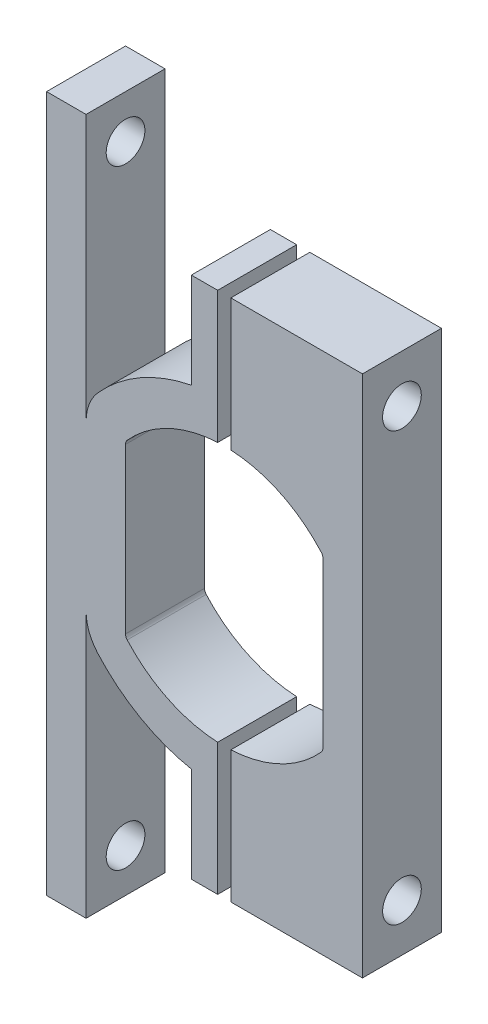
from build123d import *

# Parameters (mm, degrees)
SKETCH1_W           = 65
SKETCH1_H           = 65
BOSS_EXTRUDE1_DEPTH = 6
SKETCH3_W           = 65
SKETCH3_H           = 65
CUT_EXTRUDE2_DEPTH  = 10
BOSS_EXTRUDE2_DEPTH = 6
CUT_EXTRUDE3_REACH  = 39.726
CUT_EXTRUDE4_START  = -13
SKETCH7_R           = 1.47
CUT_EXTRUDE4_DEPTH  = 13
SKETCH8_W           = 6
SKETCH8_H           = 6.572516921
SKETCH8_R           = 1.47
SKETCH8_H_2         = 13.638765158
SKETCH8_H_3         = 12.472469684
BOSS_EXTRUDE3_DEPTH = 3


with BuildPart() as part:
    # Sketch1 → Boss-Extrude1 (new body)
    with BuildSketch(Plane.XY):
        Rectangle(SKETCH1_W, SKETCH1_H)
    extrude(amount=BOSS_EXTRUDE1_DEPTH)

    # Sketch3 → Cut-Extrude2 (cut)
    with BuildSketch(Plane.XY.offset(6)):
        Rectangle(SKETCH3_W, SKETCH3_H)
        with BuildLine():
            Line((10.5, 4.597893539), (10.5, 6.236234842))
            ThreePointArc((10.5, 6.236234842), (10.729169321, 7.481893971), (11.386666667, 8.564429183))
            ThreePointArc((11.386666667, 8.564429183), (21, 12.875), (30.613333333, 8.564429183))
            ThreePointArc((30.613333333, 8.564429183), (31.270830679, 7.481893971), (31.5, 6.236234842))
            Line((31.5, 6.236234842), (31.5, 4.597893539))
            Line((31.5, 4.597893539), (31.5, -4.597893539))
            Line((31.5, -4.597893539), (31.5, -6.236234842))
            ThreePointArc((31.5, -6.236234842), (31.270830679, -7.481893971), (30.613333333, -8.564429183))
            ThreePointArc((30.613333333, -8.564429183), (21, -12.875), (11.386666667, -8.564429183))
            ThreePointArc((11.386666667, -8.564429183), (10.729169321, -7.481893971), (10.5, -6.236234842))
            Line((10.5, -6.236234842), (10.5, -4.597893539))
            Line((10.5, -4.597893539), (10.5, 4.597893539))
        make_face(mode=Mode.SUBTRACT)
        with BuildLine():
            ThreePointArc((28.5, 6.236234842), (28.467261526, 6.414186146), (28.373333333, 6.568834033))
            ThreePointArc((28.373333333, 6.568834033), (21, 9.875), (13.626666667, 6.568834033))
            ThreePointArc((13.626666667, 6.568834033), (13.532738474, 6.414186146), (13.5, 6.236234842))
            Line((13.5, 6.236234842), (13.5, 4.597893539))
            Line((13.5, 4.597893539), (13.5, -4.597893539))
            Line((13.5, -4.597893539), (13.5, -6.236234842))
            ThreePointArc((13.5, -6.236234842), (13.532738474, -6.414186146), (13.626666667, -6.568834033))
            ThreePointArc((13.626666667, -6.568834033), (21, -9.875), (28.373333333, -6.568834033))
            ThreePointArc((28.373333333, -6.568834033), (28.467261526, -6.414186146), (28.5, -6.236234842))
            Line((28.5, -6.236234842), (28.5, -4.597893539))
            Line((28.5, -4.597893539), (28.5, 4.597893539))
            Line((28.5, 4.597893539), (28.5, 6.236234842))
        make_face()
    extrude(amount=-CUT_EXTRUDE2_DEPTH, mode=Mode.SUBTRACT)

    # Sketch4 → Boss-Extrude2 (add)
    with BuildSketch(Plane(origin=(0, 0, 0), x_dir=(-1, 0, 0), z_dir=(0, 0, -1))):
        with BuildLine():
            ThreePointArc((-30.613333333, 8.564429183), (-26.267760401, 11.748034957), (-21, 12.875))
            Line((-21, 12.875), (-21, 19.875))
            Line((-21, 19.875), (-31.5, 19.875))
            Line((-31.5, 19.875), (-31.5, 6.236234842))
            ThreePointArc((-31.5, 6.236234842), (-31.270830679, 7.481893971), (-30.613333333, 8.564429183))
        make_face()
        with BuildLine():
            Line((-21, 19.875), (-21, 12.875))
            ThreePointArc((-21, 12.875), (-19.744009381, 12.813590932), (-18.5, 12.629949525))
            Line((-18.5, 12.629949525), (-18.5, 19.875))
            Line((-18.5, 19.875), (-21, 19.875))
        make_face()
        with BuildLine():
            Line((-21, -19.875), (-18.5, -19.875))
            Line((-18.5, -19.875), (-18.5, -12.629949525))
            ThreePointArc((-18.5, -12.629949525), (-25.096582929, -12.205885192), (-30.613333333, -8.564429183))
            ThreePointArc((-30.613333333, -8.564429183), (-31.270830679, -7.481893971), (-31.5, -6.236234842))
            Line((-31.5, -6.236234842), (-31.5, -19.875))
            Line((-31.5, -19.875), (-21, -19.875))
        make_face()
    extrude(amount=-BOSS_EXTRUDE2_DEPTH)

    # Sketch6 → Cut-Extrude3 (cut, up to next)
    with BuildSketch(Plane.XY.offset(6), mode=Mode.PRIVATE) as cut_extrude3_sk1:
        with BuildLine():
            Line((21.5, 19.875), (20.5, 19.875))
            Line((20.5, 19.875), (20.5, 9.862333649))
            ThreePointArc((20.5, 9.862333649), (21, 9.875), (21.5, 9.862333649))
            Line((21.5, 9.862333649), (21.5, 19.875))
        make_face()
    cut_extrude3_tool1 = extrude(cut_extrude3_sk1.sketch, amount=-CUT_EXTRUDE3_REACH, mode=Mode.PRIVATE) & part.part
    # Sketch6 → Cut-Extrude3 (cut, up to next)
    with BuildSketch(Plane.XY.offset(6), mode=Mode.PRIVATE) as cut_extrude3_sk2:
        with BuildLine():
            Line((20.5, -19.875), (20.5, -9.862333649))
            ThreePointArc((20.5, -9.862333649), (21, -9.875), (21.5, -9.862333649))
            Line((21.5, -9.862333649), (21.5, -19.875))
            Line((21.5, -19.875), (20.5, -19.875))
        make_face()
    cut_extrude3_tool2 = extrude(cut_extrude3_sk2.sketch, amount=-CUT_EXTRUDE3_REACH, mode=Mode.PRIVATE) & part.part
    add(cut_extrude3_tool1.solids().sort_by_distance((21, 14.872889, 6))[0], mode=Mode.SUBTRACT)
    add(cut_extrude3_tool2.solids().sort_by_distance((21, -14.872889, 6))[0], mode=Mode.SUBTRACT)


with BuildPart() as cut_extrude3_piece_1:
    # of the separate pieces the step leaves, piece 1, a body of its own (cut_extrude3_pieces)
    add(part.part.solids().sort_by_distance((21.5, -19.875, 0))[0])


with BuildPart() as cut_extrude3_piece_2:
    # of the separate pieces the step leaves, piece 2, a body of its own (cut_extrude3_pieces)
    add(part.part.solids().sort_by_distance((10.5, -6.236234842, 0))[0])


with BuildPart() as cut_extrude4_tool:
    # Sketch7 → Cut-Extrude4 (new body)
    with BuildSketch(Plane.ZY.offset(-18.5).offset(CUT_EXTRUDE4_START)):
        with Locations((3, 16.252474762)):
            Circle(SKETCH7_R)
        with Locations(Location((3, -16.252474762, 0), (0, 0, 90))):
            Circle(SKETCH7_R)
    extrude(amount=CUT_EXTRUDE4_DEPTH)


with BuildPart() as cut_extrude3_piece_1_1:
    add(cut_extrude3_piece_1.part)

    # Cut-Extrude4: cut by cut_extrude4_tool
    add(cut_extrude4_tool.part, mode=Mode.SUBTRACT)


with BuildPart() as cut_extrude3_piece_2_1:
    add(cut_extrude3_piece_2.part)

    # Cut-Extrude4: cut by cut_extrude4_tool
    add(cut_extrude4_tool.part, mode=Mode.SUBTRACT)

    # Sketch8 → Boss-Extrude3 (add)
    with BuildSketch(Plane.ZY.offset(-10.5)):
        with Locations((3, -23.161258461)):
            Rectangle(SKETCH8_W, SKETCH8_H)
        with Locations((3, -23.16125846)):
            Circle(SKETCH8_R, mode=Mode.SUBTRACT)
        with Locations((3, -13.055617421)):
            Rectangle(SKETCH8_W, SKETCH8_H_2)
        with Locations((3, 0)):
            Rectangle(SKETCH8_W, SKETCH8_H_3)
        with Locations((3, 13.055617421)):
            Rectangle(SKETCH8_W, SKETCH8_H_2)
        with Locations((3, 23.161258461)):
            Rectangle(SKETCH8_W, SKETCH8_H)
        with Locations((3, 23.16125846)):
            Circle(SKETCH8_R, mode=Mode.SUBTRACT)
    extrude(amount=BOSS_EXTRUDE3_DEPTH)


solid = Compound([cut_extrude3_piece_1_1.part, cut_extrude3_piece_2_1.part])
